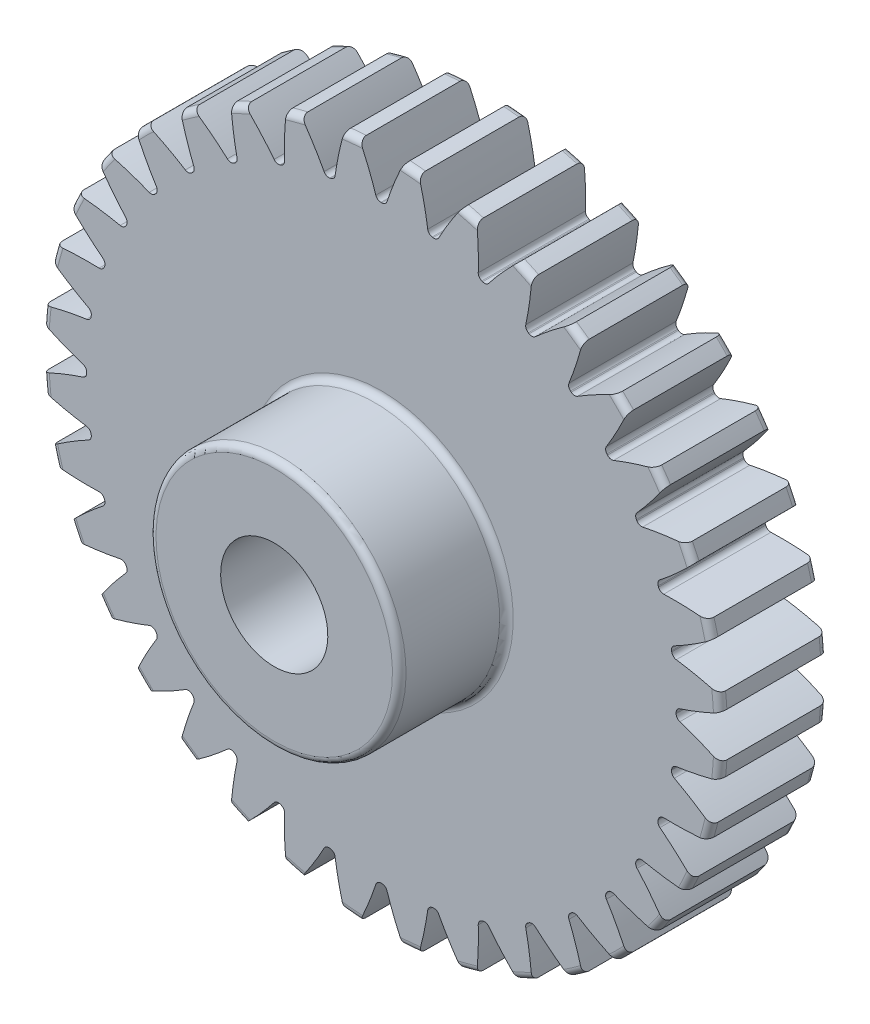
from build123d import *

# Parameters (mm, degrees)
FILLET2_R          = 0.38
CUT_EXTRUDE2_DEPTH = 28.531799796
CIRPATTERN1_COUNT  = 36


with BuildPart() as part:
    # Sketch4 → Revolve1 (revolve)
    with BuildSketch(Plane(origin=(0, 0, 0), x_dir=(0, 0, -1), z_dir=(1, 0, 0))):
        Polygon((-12, 3), (-12, 7), (-6, 7), (-6, 19), (0, 19), (0, 3), align=None)
    revolve(axis=Axis((0, 0, 6), (0, 0, 1)))

    # Fillet2
    fillet2_edges = [part.edges().sort_by_distance(p)[0] for p in [
        (0, -7, 12),
        (0, -7, 6),
        (0, -19, 6),
        (0, -19, 0),
    ]]
    fillet(fillet2_edges, radius=FILLET2_R)

    # Sketch7 → Cut-Extrude2 (cut, through all)
    with BuildSketch(Plane.XY.offset(6)):
        with BuildLine():
            ThreePointArc((-0.026603161, 16.499978554), (0, 16.5), (0.026603161, 16.499978554))
            ThreePointArc((0.026603161, 16.499978554), (0.20288747, 16.556880155), (0.312154737, 16.706461619))
            ThreePointArc((0.312154737, 16.706461619), (0.730288505, 17.848903583), (1.224636785, 18.960492207))
            ThreePointArc((1.224636785, 18.960492207), (0, 19), (-1.224636785, 18.960492207))
            ThreePointArc((-1.224636785, 18.960492207), (-0.730288505, 17.848903583), (-0.312154737, 16.706461619))
            ThreePointArc((-0.312154737, 16.706461619), (-0.20288747, 16.556880155), (-0.026603161, 16.499978554))
        make_face()
    cut_extrude2 = extrude(amount=-CUT_EXTRUDE2_DEPTH, mode=Mode.SUBTRACT)

    # CirPattern1: Cut-Extrude2 ×36 about axis
    cirpattern1_axis = Axis((0, 0, 12), (0, 0, -1))
    for i in range(1, CIRPATTERN1_COUNT):
        add(cut_extrude2.rotate(cirpattern1_axis, i * 360 / CIRPATTERN1_COUNT), mode=Mode.SUBTRACT)


solid = part.part
